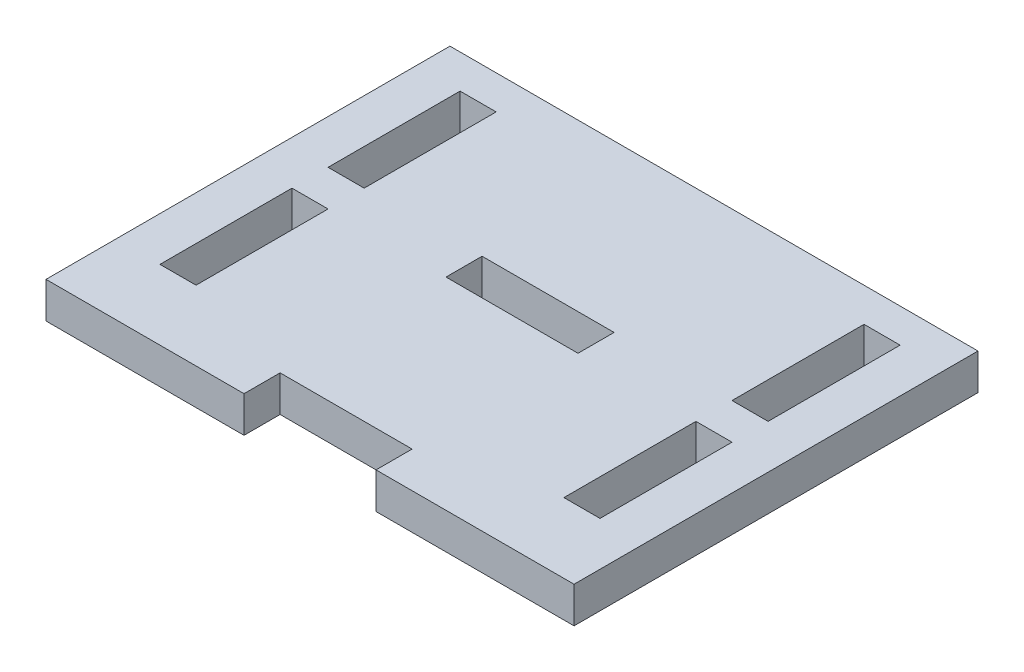
from build123d import *

# Parameters (mm, degrees)
SKETCH1_W           = 4.1
SKETCH1_H           = 15
SKETCH1_W_2         = 15
SKETCH1_H_2         = 4.1
BOSS_EXTRUDE1_DEPTH = 4.1


with BuildPart() as part:
    # Sketch1 → Boss-Extrude1 (new body)
    with BuildSketch(Plane(origin=(0, 0, 0), x_dir=(1, 0, 0), z_dir=(0, 1, 0))):
        Polygon((0, 45.9), (0, 0), (22.5, 0), (22.5, 4.1), (37.5, 4.1), (37.5, 0), (60, 0), (60, 45.9), align=None)
        with Locations((7.05, 34.55)):
            Rectangle(SKETCH1_W, SKETCH1_H, mode=Mode.SUBTRACT)
        with Locations((7.05, 15.45)):
            Rectangle(SKETCH1_W, SKETCH1_H, mode=Mode.SUBTRACT)
        with Locations((52.95, 34.55)):
            Rectangle(SKETCH1_W, SKETCH1_H, mode=Mode.SUBTRACT)
        with Locations((52.95, 15.45)):
            Rectangle(SKETCH1_W, SKETCH1_H, mode=Mode.SUBTRACT)
        with Locations((30, 25)):
            Rectangle(SKETCH1_W_2, SKETCH1_H_2, mode=Mode.SUBTRACT)
    extrude(amount=BOSS_EXTRUDE1_DEPTH)


solid = part.part
